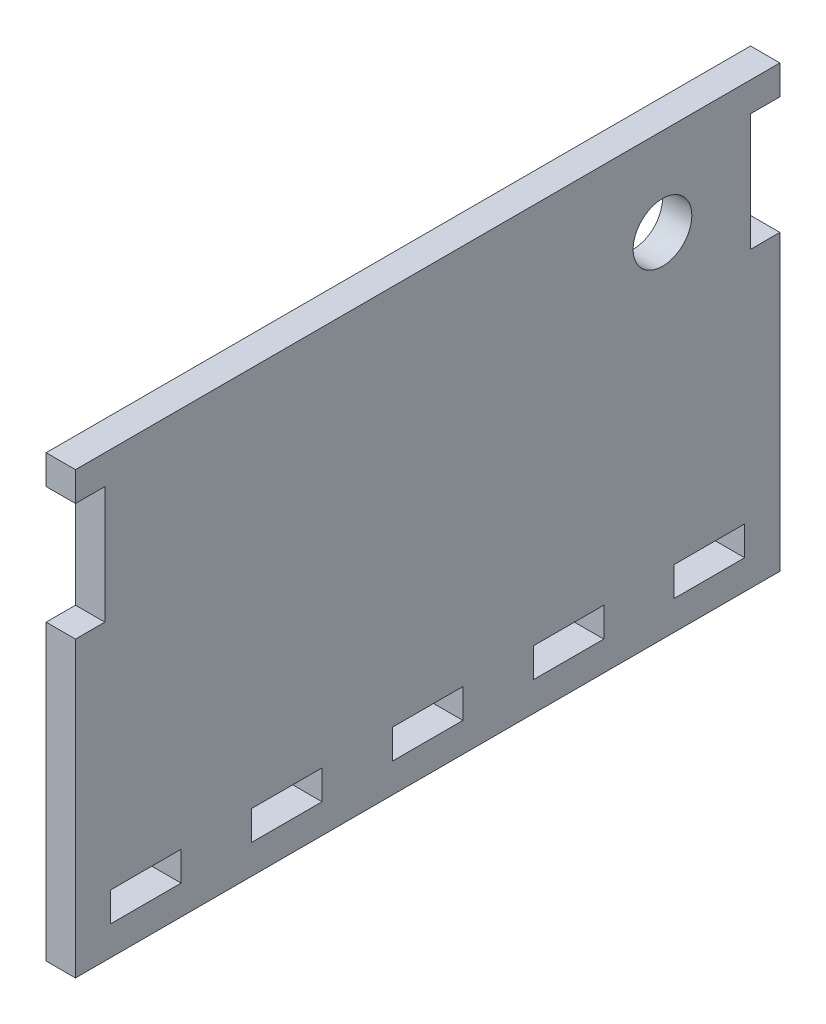
from build123d import *

# Parameters (mm, degrees)
SKETCH1_R           = 3.175
SKETCH1_W           = 7.62
SKETCH1_H           = 3.175
BOSS_EXTRUDE1_DEPTH = 1.5875


with BuildPart() as part:
    # Sketch1 → Boss-Extrude1 (new body, symmetric)
    with BuildSketch(Plane(origin=(0, 0, 0), x_dir=(0, 0, -1), z_dir=(1, 0, 0))):
        Polygon((-38.1, -23.8125), (38.1, -23.8125), (38.1, 7.9375), (34.925, 7.9375), (34.925, 20.6375), (38.1, 20.6375), (38.1, 23.8125), (-38.1, 23.8125), (-38.1, 20.6375), (-34.925, 20.6375), (-34.925, 7.9375), (-38.1, 7.9375), align=None)
        with Locations((25.4, 14.2875)):
            Circle(SKETCH1_R, mode=Mode.SUBTRACT)
        with Locations((-15.24, -19.05)):
            Rectangle(SKETCH1_W, SKETCH1_H, mode=Mode.SUBTRACT)
        with Locations((-30.48, -19.05)):
            Rectangle(SKETCH1_W, SKETCH1_H, mode=Mode.SUBTRACT)
        with Locations((0, -19.05)):
            Rectangle(SKETCH1_W, SKETCH1_H, mode=Mode.SUBTRACT)
        with Locations((15.24, -19.05)):
            Rectangle(SKETCH1_W, SKETCH1_H, mode=Mode.SUBTRACT)
        with Locations((30.48, -19.05)):
            Rectangle(SKETCH1_W, SKETCH1_H, mode=Mode.SUBTRACT)
    extrude(amount=BOSS_EXTRUDE1_DEPTH, both=True)


solid = part.part
